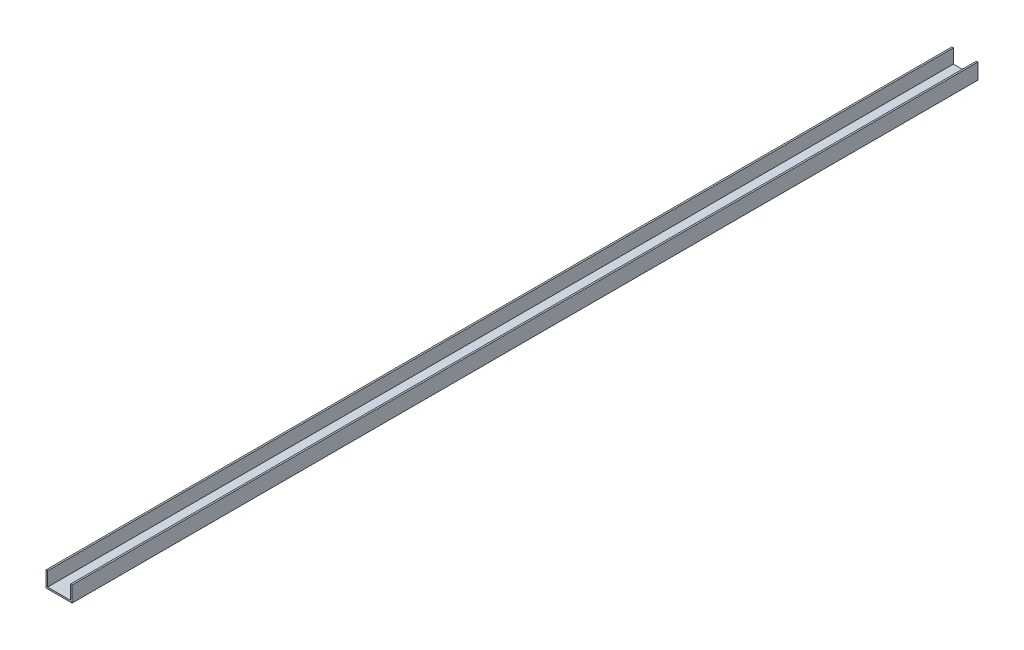
from build123d import *

# Parameters (mm, degrees)
BOSS_EXTRUDE1_DEPTH = 1732


with BuildPart() as part:
    # Sketch1 → Boss-Extrude1 (new body)
    with BuildSketch(Plane.XY):
        Polygon((-25, 0), (25, 0), (25, 30), (22, 30), (22, 3), (-22, 3), (-22, 30), (-25, 30), align=None)
    extrude(amount=BOSS_EXTRUDE1_DEPTH)


solid = part.part
